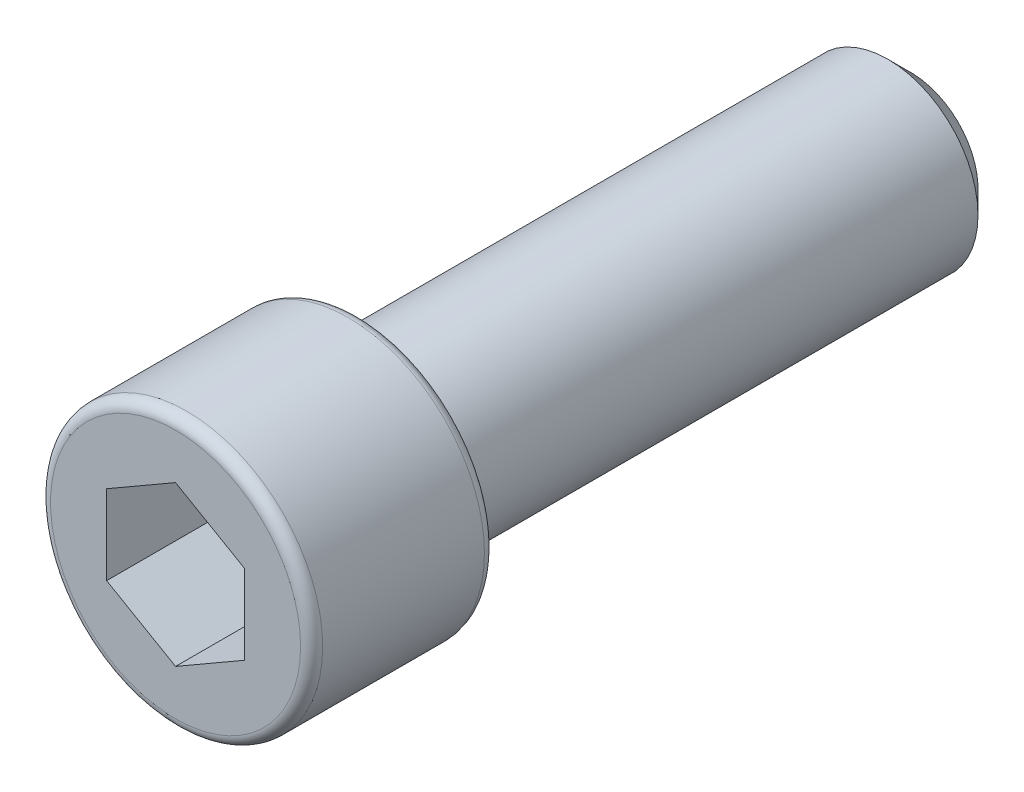
from build123d import *

# Parameters (mm, degrees)
SKETCH1_W      = 4.699
SKETCH1_H      = 6.35
SKETCH2_R      = 3.1115
EXTRUDE1_DEPTH = 19.05
EXTRUDE2_DEPTH = 3.81
CHAMFER1_SIZE2 = 0.793750001
CHAMFER1_SIZE  = 0.793749999
FILLET1_R      = 0.381
FILLET2_R      = 0.381


with BuildPart() as part:
    # Sketch1 → Revolve1 (revolve)
    with BuildSketch(Plane(origin=(0, 0, 0), x_dir=(1, 0, 0), z_dir=(0, 1, 0))):
        with Locations((2.3495, -3.175)):
            Rectangle(SKETCH1_W, SKETCH1_H)
    revolve(axis=Axis((0, 0, 0), (0, 0, 1)))

    # Sketch2 → Extrude1 (add)
    with BuildSketch(Plane(origin=(0, 0, 0), x_dir=(-1, 0, 0), z_dir=(0, 0, -1))):
        Circle(SKETCH2_R)
    extrude(amount=EXTRUDE1_DEPTH)

    # Sketch3 → Extrude2 (cut)
    with BuildSketch(Plane.XY.offset(6.35)):
        Polygon((2.38125, 1.374815329), (0, 2.749630657), (-2.38125, 1.374815329), (-2.38125, -1.374815329), (0, -2.749630657), (2.38125, -1.374815329), align=None)
    extrude(amount=-EXTRUDE2_DEPTH, mode=Mode.SUBTRACT)

    # Chamfer1
    chamfer1_edges = [part.edges().sort_by_distance(p)[0] for p in [
        (3.1115, 0, -19.05),
    ]]
    chamfer(chamfer1_edges, length=CHAMFER1_SIZE, length2=CHAMFER1_SIZE2)

    # Fillet1
    fillet1_edges = [part.edges().sort_by_distance(p)[0] for p in [
        (-4.699, 0, 6.35),
    ]]
    fillet(fillet1_edges, radius=FILLET1_R)

    # Fillet2
    fillet2_edges = [part.edges().sort_by_distance(p)[0] for p in [
        (-4.699, 0, 0),
    ]]
    fillet(fillet2_edges, radius=FILLET2_R)


solid = part.part
